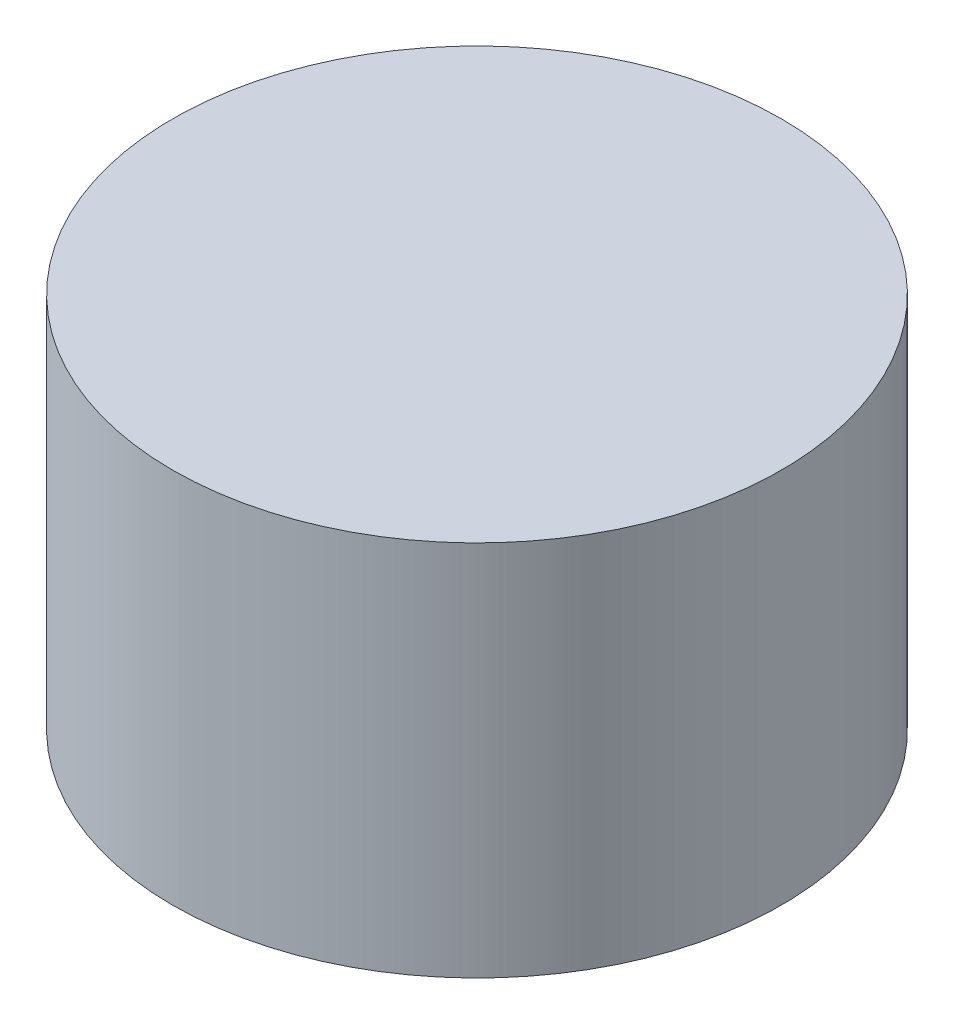
from build123d import *

# Parameters (mm, degrees)
SKETCH1_R           = 10.5
BOSS_EXTRUDE1_DEPTH = 13
SKETCH2_W           = 7.5
SKETCH2_H           = 10


with BuildPart() as part:
    # Sketch1 → Boss-Extrude1 (new body)
    with BuildSketch(Plane(origin=(0, 0, 0), x_dir=(1, 0, 0), z_dir=(0, 1, 0))):
        Circle(SKETCH1_R)
    extrude(amount=BOSS_EXTRUDE1_DEPTH)

    # Sketch2 → Cut-Revolve2 (revolve, cut)
    with BuildSketch(Plane(origin=(0, 0, 0), x_dir=(0, 0, -1), z_dir=(1, 0, 0))):
        with Locations((3.75, 3.17408016)):
            Rectangle(SKETCH2_W, SKETCH2_H)
    revolve(axis=Axis((0, 0.049098768, 0), (0, 1, 0)), mode=Mode.SUBTRACT)


solid = part.part
